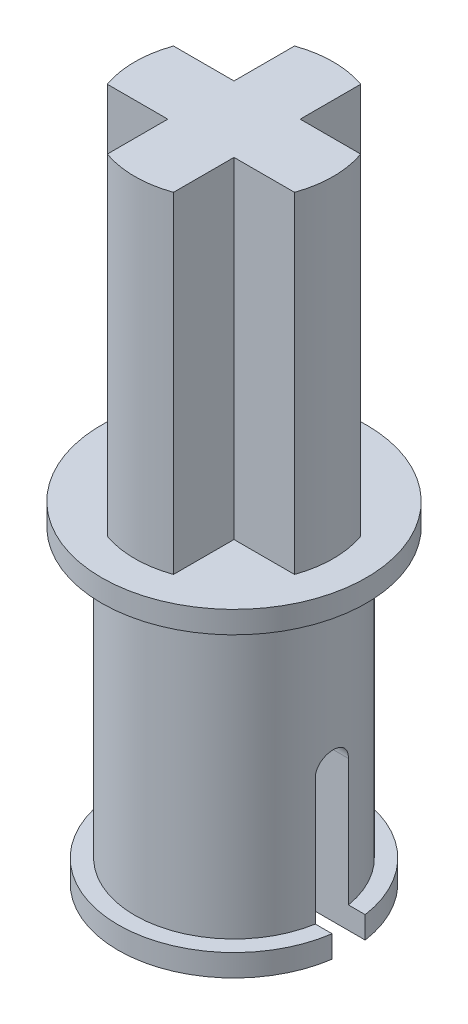
from build123d import *

# Parameters (mm, degrees)
SKETCH1_R               = 1.5
SKETCH1_R_2             = 1
BOSS_EXTRUDE1_DEPTH     = 5
SKETCH2_R               = 2
SKETCH2_R_2             = 1.5
SKETCH2_R_3             = 1
BOSS_EXTRUDE2_DEPTH     = 0.333333333
SKETCH3_R               = 1.75
SKETCH3_R_2             = 1
BOSS_EXTRUDE4_DEPTH     = 0.333333333
SKETCH4_R               = 0.25
SKETCH4_W               = 0.5
SKETCH4_H               = 2.25
CUT_EXTRUDE1_DEPTH      = 6.744562647
CUT_EXTRUDE1_DEPTH_BACK = 6.744562647
SKETCH7_W               = 1
SKETCH7_H               = 1
BOSS_EXTRUDE6_DEPTH     = 5


with BuildPart() as part:
    # Sketch1 → Boss-Extrude1 (new body)
    with BuildSketch(Plane(origin=(0, 0, 0), x_dir=(1, 0, 0), z_dir=(0, 1, 0))):
        with Locations(Location((0, 0, 0), (0, 0, 270))):
            Circle(SKETCH1_R)
        with Locations(Location((0, 0, 0), (0, 0, 270))):
            Circle(SKETCH1_R_2, mode=Mode.SUBTRACT)
    extrude(amount=BOSS_EXTRUDE1_DEPTH)

    # Sketch2 → Boss-Extrude2 (add)
    with BuildSketch(Plane(origin=(0, 5, 0), x_dir=(1, 0, 0), z_dir=(0, 1, 0))):
        with Locations(Location((0, 0, 0), (0, 0, 270))):
            Circle(SKETCH2_R)
        with Locations(Location((0, 0, 0), (0, 0, 270))):
            Circle(SKETCH2_R_2, mode=Mode.SUBTRACT)
        with Locations(Location((0, 0, 0), (0, 0, 270))):
            Circle(SKETCH2_R_2)
        with Locations(Location((0, 0, 0), (0, 0, 270))):
            Circle(SKETCH2_R_3, mode=Mode.SUBTRACT)
        with Locations(Location((0, 0, 0), (0, 0, 270))):
            Circle(SKETCH2_R_3)
    extrude(amount=-BOSS_EXTRUDE2_DEPTH)

    # Sketch3 → Boss-Extrude4 (add)
    with BuildSketch(Plane(origin=(0, 0, 0), x_dir=(-1, 0, 0), z_dir=(0, -1, 0))):
        with Locations(Location((0, 0, 0), (0, 0, 90))):
            Circle(SKETCH3_R)
        with Locations(Location((0, 0, 0), (0, 0, 270))):
            Circle(SKETCH3_R_2, mode=Mode.SUBTRACT)
    extrude(amount=-BOSS_EXTRUDE4_DEPTH)

    # Sketch4 → Cut-Extrude1 (cut, two sides)
    with BuildSketch(Plane(origin=(0, 0, 0), x_dir=(0, 0, -1), z_dir=(1, 0, 0))) as cut_extrude1_sk:
        with Locations((0, 2.25)):
            Circle(SKETCH4_R)
        with Locations((0, 1.125)):
            Rectangle(SKETCH4_W, SKETCH4_H)
    extrude(amount=CUT_EXTRUDE1_DEPTH, mode=Mode.SUBTRACT)
    extrude(cut_extrude1_sk.sketch, amount=-CUT_EXTRUDE1_DEPTH_BACK, mode=Mode.SUBTRACT)

    # Sketch7 → Boss-Extrude6 (add)
    with BuildSketch(Plane(origin=(0, 5, 0), x_dir=(1, 0, 0), z_dir=(0, 1, 0))):
        with BuildLine():
            Line((1.414213562, 0.5), (0.5, 0.5))
            Line((0.5, 0.5), (0.5, -0.5))
            Line((0.5, -0.5), (1.414213562, -0.5))
            ThreePointArc((1.414213562, -0.5), (1.478397839, -0.253652968), (1.5, 0))
            ThreePointArc((1.5, 0), (1.478397839, 0.253652968), (1.414213562, 0.5))
        make_face()
        Rectangle(SKETCH7_W, SKETCH7_H)
        with BuildLine():
            Line((0.5, -0.5), (-0.5, -0.5))
            Line((-0.5, -0.5), (-0.5, -1.414213562))
            ThreePointArc((-0.5, -1.414213562), (-0.253652968, -1.478397839), (0, -1.5))
            ThreePointArc((0, -1.5), (0.253652968, -1.478397839), (0.5, -1.414213562))
            Line((0.5, -1.414213562), (0.5, -0.5))
        make_face()
        with BuildLine():
            ThreePointArc((0.5, 1.414213562), (0.253652968, 1.478397839), (0, 1.5))
            ThreePointArc((0, 1.5), (-0.253652968, 1.478397839), (-0.5, 1.414213562))
            Line((-0.5, 1.414213562), (-0.5, 0.5))
            Line((-0.5, 0.5), (0.5, 0.5))
            Line((0.5, 0.5), (0.5, 1.414213562))
        make_face()
        with BuildLine():
            Line((-0.5, -0.5), (-0.5, 0.5))
            Line((-0.5, 0.5), (-1.414213562, 0.5))
            ThreePointArc((-1.414213562, 0.5), (-1.478397839, 0.253652968), (-1.5, 0))
            ThreePointArc((-1.5, 0), (-1.478397839, -0.253652968), (-1.414213562, -0.5))
            Line((-1.414213562, -0.5), (-0.5, -0.5))
        make_face()
    extrude(amount=BOSS_EXTRUDE6_DEPTH)


solid = part.part
